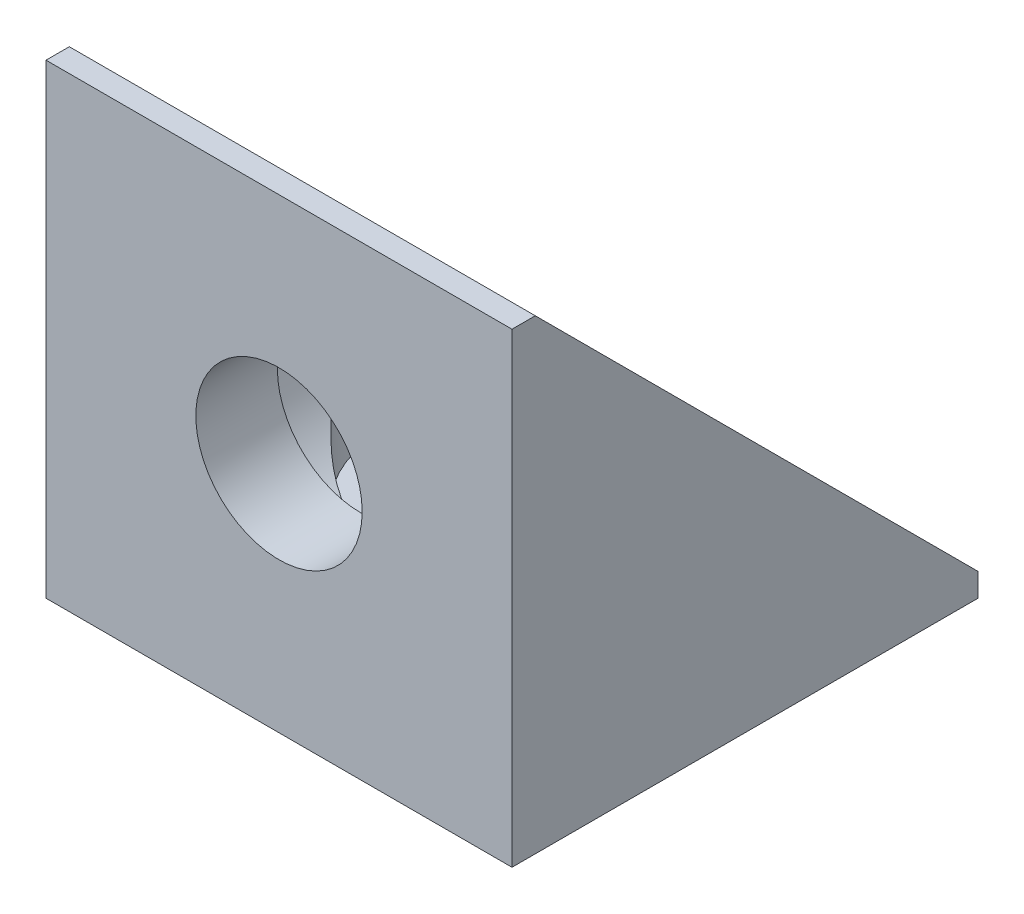
from build123d import *

# Parameters (mm, degrees)
BOSS_EXTRU_1_DEPTH      = 10
ESQUISSE2_R             = 3.57
ENL_V_MAT_EXTRU_1_DEPTH = 21
ESQUISSE3_R             = 5.5
ENL_V_MAT_EXTRU_2_DEPTH = 16.5
ESQUISSE5_R             = 3.57
ENL_V_MAT_EXTRU_3_DEPTH = 21
ESQUISSE6_R             = 5.5
ENL_V_MAT_EXTRU_4_DEPTH = 16.5


with BuildPart() as part:
    # Esquisse1 → Boss.-Extru.1 (new body, symmetric)
    with BuildSketch(Plane(origin=(0, 0, 0), x_dir=(0, 0, -1), z_dir=(1, 0, 0))):
        Polygon((20, 0), (0, 0), (0, 20), (1, 20), (20, 1), align=None)
    extrude(amount=BOSS_EXTRU_1_DEPTH, both=True)

    # Esquisse2 → Enlèv. mat.-Extru.1 (cut, through all)
    with BuildSketch(Plane.XZ):
        with Locations((0, -10)):
            Circle(ESQUISSE2_R)
    extrude(amount=-ENL_V_MAT_EXTRU_1_DEPTH, mode=Mode.SUBTRACT)

    # Esquisse3 → Enlèv. mat.-Extru.2 (cut)
    with BuildSketch(Plane(origin=(0, 20, 0), x_dir=(1, 0, 0), z_dir=(0, 1, 0))):
        with Locations((0, 10)):
            Circle(ESQUISSE3_R)
    extrude(amount=-ENL_V_MAT_EXTRU_2_DEPTH, mode=Mode.SUBTRACT)

    # Esquisse5 → Enlèv. mat.-Extru.3 (cut, through all)
    with BuildSketch(Plane.XY):
        with Locations((0, 10)):
            Circle(ESQUISSE5_R)
    extrude(amount=-ENL_V_MAT_EXTRU_3_DEPTH, mode=Mode.SUBTRACT)

    # Esquisse6 → Enlèv. mat.-Extru.4 (cut)
    with BuildSketch(Plane(origin=(0, 0, -20), x_dir=(-1, 0, 0), z_dir=(0, 0, -1))):
        with Locations((0, 10)):
            Circle(ESQUISSE6_R)
    extrude(amount=-ENL_V_MAT_EXTRU_4_DEPTH, mode=Mode.SUBTRACT)


solid = part.part
